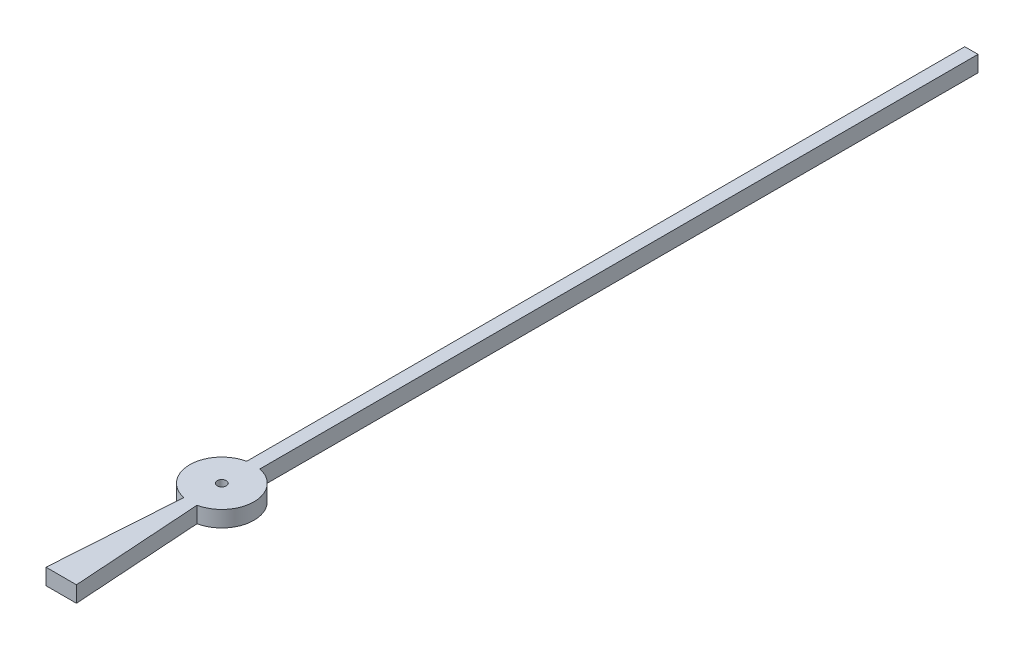
from build123d import *

# Parameters (mm, degrees)
BOSS_EXTRUDE1_DEPTH = 0.3
SKETCH2_R           = 0.085
CUT_EXTRUDE1_DEPTH  = 0.3


with BuildPart() as part:
    # Sketch1 → Boss-Extrude1 (new body)
    with BuildSketch(Plane(origin=(0, 0, 0), x_dir=(1, 0, 0), z_dir=(0, 1, 0))):
        with BuildLine():
            Line((0.284268307, -3), (-0.284268307, -3))
            Line((-0.284268307, -3), (-0.123615756, -0.587127878))
            ThreePointArc((-0.123615756, -0.587127878), (-0.6, 0), (-0.123615756, 0.587127878))
            Line((-0.123615756, 0.587127878), (-0.123615756, 14))
            Line((-0.123615756, 14), (0.123615756, 14))
            Line((0.123615756, 14), (0.123615756, 0.587127878))
            ThreePointArc((0.123615756, 0.587127878), (0.6, 0), (0.123615756, -0.587127878))
            Line((0.123615756, -0.587127878), (0.284268307, -3))
        make_face()
    extrude(amount=BOSS_EXTRUDE1_DEPTH)

    # Sketch2 → Cut-Extrude1 (cut)
    with BuildSketch(Plane(origin=(0, 0.3, 0), x_dir=(1, 0, 0), z_dir=(0, 1, 0))):
        Circle(SKETCH2_R)
    extrude(amount=-CUT_EXTRUDE1_DEPTH, mode=Mode.SUBTRACT)


solid = part.part
